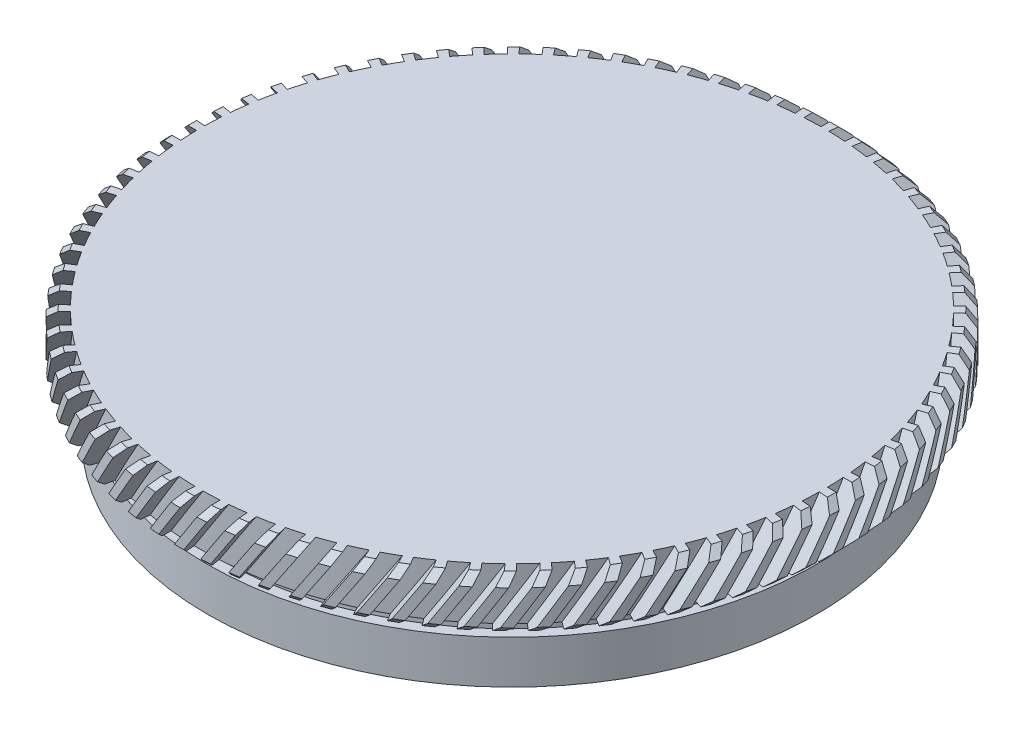
from build123d import *

# Parameters (mm, degrees)
CHAMFER_1_SIZE           = 0.5
CUT_EXTRUDE_1_REACH      = 66.701
CUT_EXTRUDE_1_END_RADIUS = 18.05
CUT_EXTRUDE_START        = 30
PATTERN_CIRCULAR_2_COUNT = 80


with BuildPart() as part:
    # 草图1 → 旋转2 (revolve)
    with BuildSketch(Plane.XY, mode=Mode.PRIVATE) as revolve_2_sk:
        Polygon((0, 21.871257405), (19.05, 21.871257405), (19.05, 18.871257405), (17, 18.871257405), (17, 17.871257405), (17.6, 17.871257405), (17.6, 15.371257405), (15.75, 15.371257405), (15.75, 18.871257405), (0, 18.871257405), align=None)
    revolve(revolve_2_sk.sketch.rotate(Axis((0, 66.628762136, 0), (0, -1, 0)), 90), axis=Axis((0, 66.628762136, 0), (0, -1, 0)))

    # 倒角1
    chamfer_1_edges = [part.edges().sort_by_distance(p)[0] for p in [
        (0, 21.871257405, -19.05),
        (0, 18.871257405, -19.05),
    ]]
    chamfer(chamfer_1_edges, length=CHAMFER_1_SIZE)

    # 切除-拉伸1: up to this cylinder (the profile starts outside it)
    cut_extrude_1_end = Plane(origin=(0, 18.072086, 0), z_dir=(0, 1, 0)) * Cylinder(CUT_EXTRUDE_1_END_RADIUS, 170.502, mode=Mode.PRIVATE)
    # 草图2 → 切除-拉伸1 (cut, up to the surface)
    with BuildSketch(Plane.XY.offset(CUT_EXTRUDE_START), mode=Mode.PRIVATE) as cut_extrude_1_sk1:
        Polygon((1.108168834, 23.303253722), (-5.339513804, 13.273525174), (-4.666571024, 12.840919101), (1.781111614, 22.870647649), align=None)
    cut_extrude_1_tool1 = extrude(cut_extrude_1_sk1.sketch, amount=-CUT_EXTRUDE_1_REACH, mode=Mode.PRIVATE) - cut_extrude_1_end
    cut_extrude_1 = cut_extrude_1_tool1.solids().sort_by_distance((-1.779201, 18.072086, 30))[0]
    add(cut_extrude_1, mode=Mode.SUBTRACT)

    # 阵列(圆周)2: 切除-拉伸1 ×80 about axis
    pattern_circular_2_axis = Axis((0, 0, 0), (0, 1, 0))
    for i in range(1, PATTERN_CIRCULAR_2_COUNT):
        add(cut_extrude_1.rotate(pattern_circular_2_axis, i * 360 / PATTERN_CIRCULAR_2_COUNT), mode=Mode.SUBTRACT)


solid = part.part
